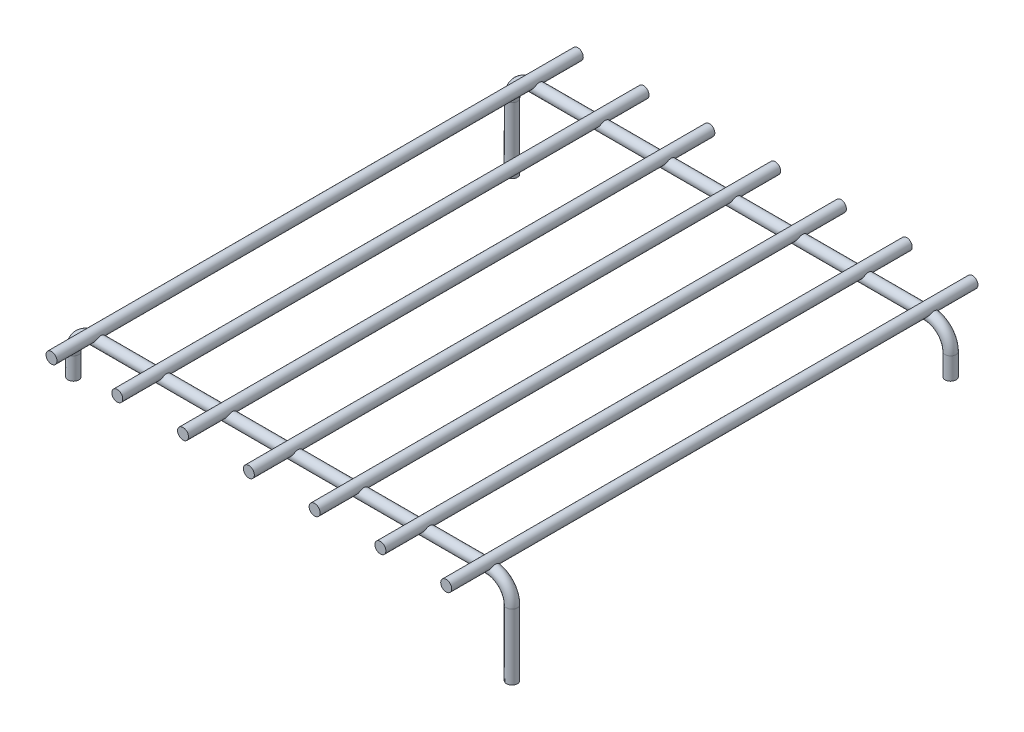
from build123d import *

# Parameters (mm, degrees)
SKETCH2_R           = 1.5875
LPATTERN1_COUNT     = 2
LPATTERN1_PITCH     = 127
SKETCH3_R           = 1.5875
EXTRUDE1_DEPTH      = 12.7
EXTRUDE1_DEPTH_BACK = 139.7
LPATTERN2_COUNT     = 4
LPATTERN2_PITCH     = 19.05
LPATTERN2_2_COUNT   = 4
LPATTERN2_2_PITCH   = 19.05
SKETCH4_R           = 1.5875
EXTRUDE2_DEPTH      = 12.7
SKETCH5_R           = 1.5875
CUT_EXTRUDE1_DEPTH  = 12.7


with BuildPart() as part:
    # Sweep1: sweep along a path in Sketch1
    with BuildLine(Plane.XY) as sweep1_path:
        Line((-63.5, -12.7), (-63.5, -6.35))
        ThreePointArc((-63.5, -6.35), (-61.640128061, -1.859871939), (-57.15, 0))
        Line((-57.15, 0), (57.15, 0))
        ThreePointArc((57.15, 0), (61.640128061, -1.859871939), (63.5, -6.35))
        Line((63.5, -6.35), (63.5, -25.4))
    # Sketch2 → Sweep1 (sweep)
    with BuildSketch(Plane(origin=(-63.5, -12.7, 0), x_dir=(-1, 0, 0), z_dir=(0, 1, 0))):
        Circle(SKETCH2_R)
    sweep(path=sweep1_path.line)


with BuildPart() as lpattern1_1:
    # LPattern1: pattern copy
    add(part.part.moved(Location(Vector(0, 0, -1) * (1 * LPATTERN1_PITCH))))


with BuildPart() as body_3:
    # Sketch3 → Extrude1 (new body, two sides)
    with BuildSketch(Plane.XY) as extrude1_sk:
        with Locations((0, 1.5875)):
            Circle(SKETCH3_R)
    extrude(amount=EXTRUDE1_DEPTH)
    extrude(extrude1_sk.sketch, amount=-EXTRUDE1_DEPTH_BACK)


with BuildPart() as lpattern2_1:
    # LPattern2: pattern copy
    add(body_3.part.moved(Location(Vector(1, 0, 0) * (1 * LPATTERN2_PITCH))))


with BuildPart() as lpattern2_2:
    # LPattern2: pattern copy
    add(body_3.part.moved(Location(Vector(1, 0, 0) * (2 * LPATTERN2_PITCH))))


with BuildPart() as lpattern2_3:
    # LPattern2: pattern copy
    add(body_3.part.moved(Location(Vector(1, 0, 0) * (3 * LPATTERN2_PITCH))))


with BuildPart() as lpattern2_2_1:
    # LPattern2 2: pattern copy
    add(body_3.part.moved(Location(Vector(-1, 0, 0) * (1 * LPATTERN2_2_PITCH))))


with BuildPart() as lpattern2_2_2:
    # LPattern2 2: pattern copy
    add(body_3.part.moved(Location(Vector(-1, 0, 0) * (2 * LPATTERN2_2_PITCH))))


with BuildPart() as lpattern2_2_3:
    # LPattern2 2: pattern copy
    add(body_3.part.moved(Location(Vector(-1, 0, 0) * (3 * LPATTERN2_2_PITCH))))


with BuildPart() as part_1:
    add(part.part)

    # Combine1: union LPattern1_1, body 3, LPattern2_1, LPattern2_2, LPattern2_3, LPattern2 2_1, LPattern2 2_2, LPattern2 2_3
    add(lpattern1_1.part)
    add(body_3.part)
    add(lpattern2_1.part)
    add(lpattern2_2.part)
    add(lpattern2_3.part)
    add(lpattern2_2_1.part)
    add(lpattern2_2_2.part)
    add(lpattern2_2_3.part)

    # Sketch4 → Extrude2 (add)
    with BuildSketch(Plane.XZ.offset(12.7)):
        with Locations((-63.5, -127)):
            Circle(SKETCH4_R)
    extrude(amount=EXTRUDE2_DEPTH)

    # Sketch5 → Cut-Extrude1 (cut)
    with BuildSketch(Plane.XZ.offset(25.4)):
        with Locations((63.5, -127)):
            Circle(SKETCH5_R)
    extrude(amount=-CUT_EXTRUDE1_DEPTH, mode=Mode.SUBTRACT)


solid = part_1.part
